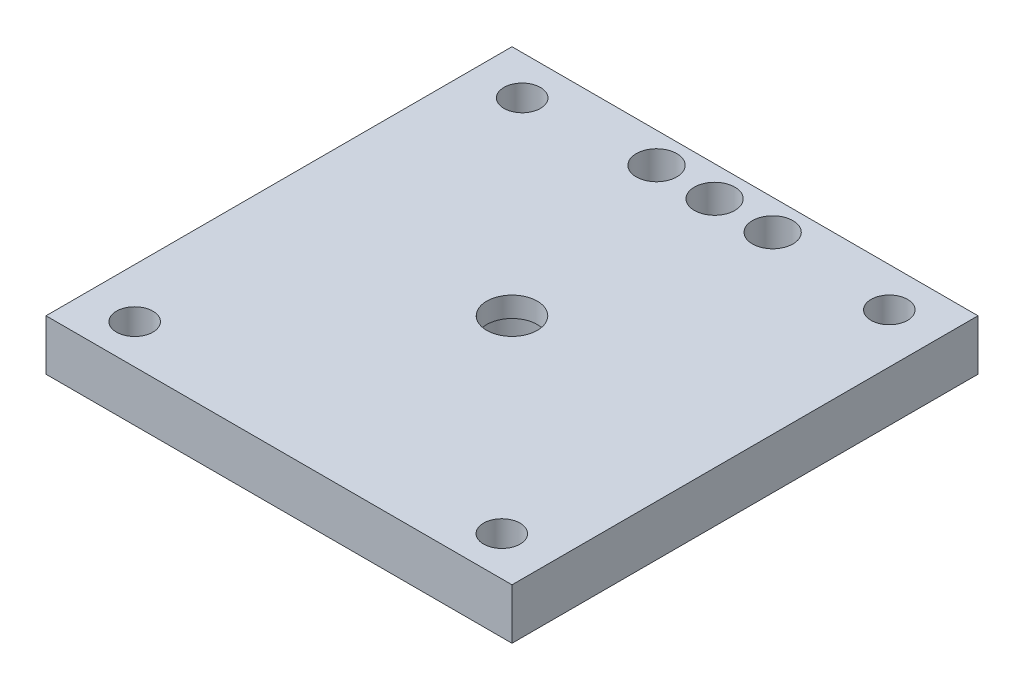
from build123d import *

# Parameters (mm, degrees)
SKETCH2_W           = 46
SKETCH2_H           = 46
BOSS_EXTRUDE1_DEPTH = 5
SKETCH3_R           = 1.8
SKETCH3_R_2         = 2.5
CUT_EXTRUDE1_DEPTH  = 5
SKETCH4_R           = 4.1
CUT_EXTRUDE2_DEPTH  = 3
SKETCH5_W           = 4
SKETCH5_H           = 4
BOSS_EXTRUDE2_DEPTH = 3
SKETCH9_R           = 2
CUT_EXTRUDE6_DEPTH  = 6


with BuildPart() as part:
    # Sketch2 → Boss-Extrude1 (new body)
    with BuildSketch(Plane(origin=(0, 0, 0), x_dir=(1, 0, 0), z_dir=(0, 1, 0))):
        Rectangle(SKETCH2_W, SKETCH2_H)
    extrude(amount=BOSS_EXTRUDE1_DEPTH)

    # Sketch3 → Cut-Extrude1 (cut)
    with BuildSketch(Plane(origin=(0, 0, 0), x_dir=(1, 0, 0), z_dir=(0, 1, 0))):
        with Locations((-18.12, 19.125)):
            Circle(SKETCH3_R)
        with Locations((18.12, 19.125)):
            Circle(SKETCH3_R)
        with Locations((18.12, -19.125)):
            Circle(SKETCH3_R)
        with Locations((-18.12, -19.125)):
            Circle(SKETCH3_R)
        Circle(SKETCH3_R_2)
    extrude(amount=CUT_EXTRUDE1_DEPTH, mode=Mode.SUBTRACT)

    # Sketch4 → Cut-Extrude2 (cut)
    with BuildSketch(Plane(origin=(0, 0, 0), x_dir=(1, 0, 0), z_dir=(0, 1, 0))):
        Circle(SKETCH4_R)
    extrude(amount=CUT_EXTRUDE2_DEPTH, mode=Mode.SUBTRACT)

    # Sketch5 → Boss-Extrude2 (add)
    with BuildSketch(Plane(origin=(0, 0, 0), x_dir=(1, 0, 0), z_dir=(0, 1, 0))):
        with Locations((-5.7330026, 5.06948708)):
            Rectangle(SKETCH5_W, SKETCH5_H)
        with Locations((5.862376563, -4.939727226)):
            Rectangle(SKETCH5_W, SKETCH5_H)
    extrude(amount=-BOSS_EXTRUDE2_DEPTH)

    # Sketch9 → Cut-Extrude6 (cut, through all)
    with BuildSketch(Plane(origin=(0, 0, 0), x_dir=(1, 0, 0), z_dir=(0, 1, 0))):
        with Locations((-5.7330026, 20)):
            Circle(SKETCH9_R)
        with Locations((5.73, 20)):
            Circle(SKETCH9_R)
        with Locations((0, 20)):
            Circle(SKETCH9_R)
    extrude(amount=CUT_EXTRUDE6_DEPTH, mode=Mode.SUBTRACT)


solid = part.part
